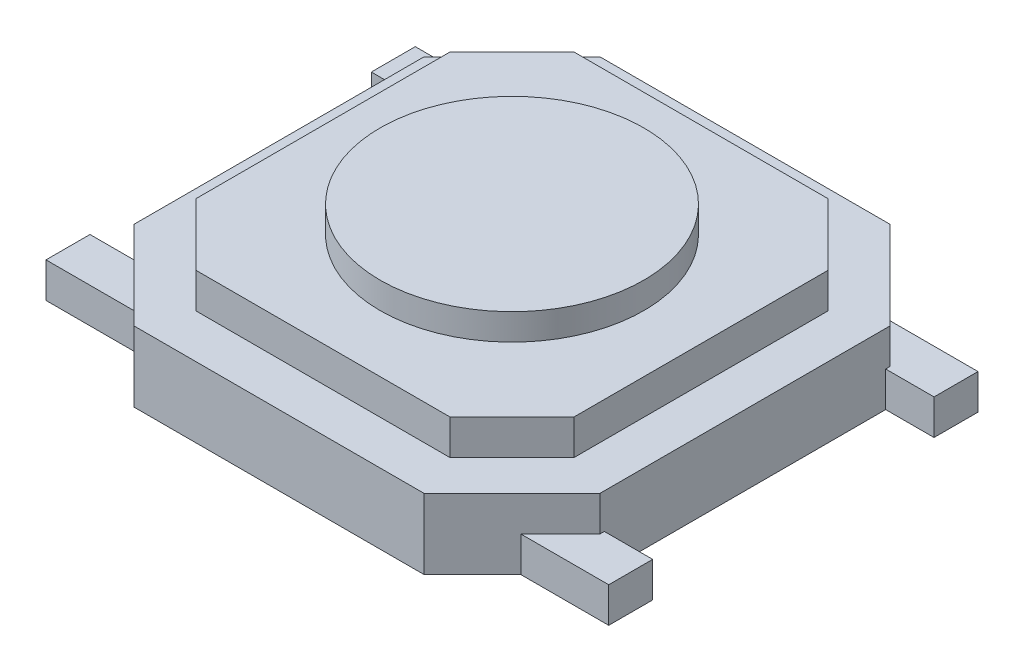
from build123d import *

# Parameters (mm, degrees)
EXTRUDE1_DEPTH = 0.4
EXTRUDE2_DEPTH = 0.8
EXTRUDE3_DEPTH = 1.2
SKETCH4_R      = 1.5
EXTRUDE7_DEPTH = 1.5


with BuildPart() as part:
    # Sketch1 → Extrude1 (new body)
    with BuildSketch(Plane(origin=(0, 0, 0), x_dir=(1, 0, 0), z_dir=(0, 1, 0))):
        Polygon((-3.2, 2.1), (3.2, 2.1), (3.2, 1.6), (2.2, 1.6), (2.2, -1.6), (3.2, -1.6), (3.2, -2.1), (-3.2, -2.1), (-3.2, -1.6), (-2.2, -1.6), (-2.2, 1.6), (-3.2, 1.6), align=None)
    extrude(amount=EXTRUDE1_DEPTH)

    # Sketch2 → Extrude2 (add)
    with BuildSketch(Plane(origin=(0, 0, 0), x_dir=(-1, 0, 0), z_dir=(0, 1, 0))):
        Polygon((1.65, -2.65), (2.65, -1.65), (2.65, 1.65), (1.65, 2.65), (-1.65, 2.65), (-2.65, 1.65), (-2.65, -1.65), (-1.65, -2.65), align=None)
    extrude(amount=EXTRUDE2_DEPTH)

    # Sketch3 → Extrude3 (add)
    with BuildSketch(Plane(origin=(0, 0, 0), x_dir=(-1, 0, 0), z_dir=(0, 1, 0))):
        Polygon((-2.15, 1.442893219), (-2.15, -1.442893219), (-1.442893219, -2.15), (1.442893219, -2.15), (2.15, -1.442893219), (2.15, 1.442893219), (1.442893219, 2.15), (-1.442893219, 2.15), align=None)
    extrude(amount=EXTRUDE3_DEPTH)

    # Sketch4 → Extrude7 (add)
    with BuildSketch(Plane(origin=(0, 0, 0), x_dir=(-1, 0, 0), z_dir=(0, 1, 0))):
        with Locations(Location((0, 0, 0), (0, 0, 90))):  # turned: the seam where the file's is
            Circle(SKETCH4_R)
    extrude(amount=EXTRUDE7_DEPTH)


solid = part.part
